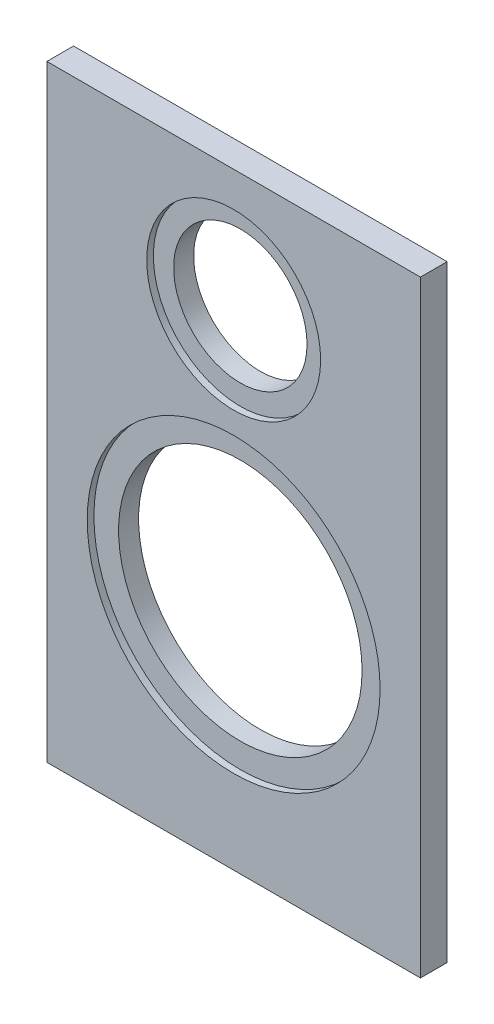
from build123d import *

# Parameters (mm, degrees)
SKETCH1_W           = 224
SKETCH1_H           = 364
BOSS_EXTRUDE1_DEPTH = 16
SKETCH2_R           = 52.15
SKETCH2_R_2         = 87.8
CUT_EXTRUDE1_DEPTH  = 4
SKETCH3_R           = 40
SKETCH3_R_2         = 73
CUT_EXTRUDE2_DEPTH  = 17


with BuildPart() as part:
    # Sketch1 → Boss-Extrude1 (new body)
    with BuildSketch(Plane.XY):
        Rectangle(SKETCH1_W, SKETCH1_H)
    extrude(amount=BOSS_EXTRUDE1_DEPTH)

    # Sketch2 → Cut-Extrude1 (cut)
    with BuildSketch(Plane.XY.offset(16)):
        with Locations((0, 109)):
            Circle(SKETCH2_R)
        with Locations((0, -44)):
            Circle(SKETCH2_R_2)
    extrude(amount=-CUT_EXTRUDE1_DEPTH, mode=Mode.SUBTRACT)

    # Sketch3 → Cut-Extrude2 (cut, through all)
    with BuildSketch(Plane.XY.offset(16)):
        with Locations((0, 109)):
            Circle(SKETCH3_R)
        with Locations((0, -44)):
            Circle(SKETCH3_R_2)
    extrude(amount=-CUT_EXTRUDE2_DEPTH, mode=Mode.SUBTRACT)


solid = part.part
